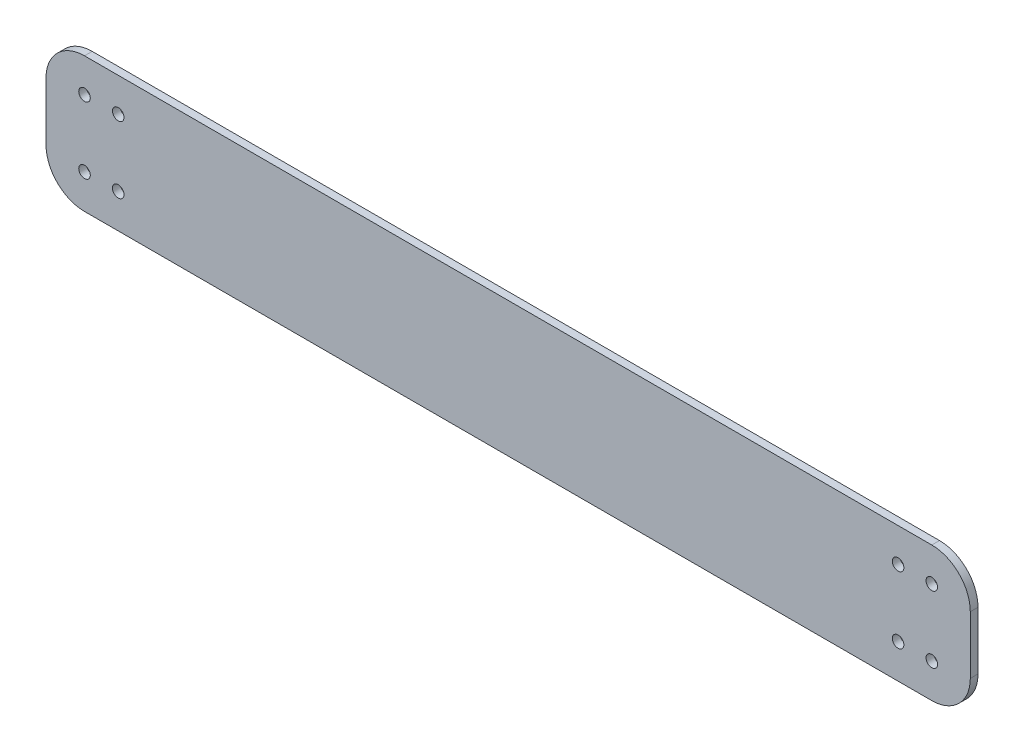
from build123d import *

# Parameters (mm, degrees)
EXTRUDE_1_DEPTH = 2
MM_2_D          = 3
MM_3_D          = 3


with BuildPart() as part:
    # 草图2 → 凸台-拉伸1 (new body)
    with BuildSketch(Plane.XY):
        with BuildLine():
            Line((-50.360367403, 22.370399323), (169.639632597, 22.370399323))
            ThreePointArc((169.639632597, 22.370399323), (176.710700409, 19.441467134), (179.639632597, 12.370399323))
            Line((179.639632597, 12.370399323), (179.639632597, -2.629600677))
            ThreePointArc((179.639632597, -2.629600677), (176.710700409, -9.700668489), (169.639632597, -12.629600677))
            Line((169.639632597, -12.629600677), (-50.360367403, -12.629600677))
            ThreePointArc((-50.360367403, -12.629600677), (-57.431435215, -9.700668489), (-60.360367403, -2.629600677))
            Line((-60.360367403, -2.629600677), (-60.360367403, 12.370399323))
            ThreePointArc((-60.360367403, 12.370399323), (-57.431435215, 19.441467134), (-50.360367403, 22.370399323))
        make_face()
    extrude(amount=EXTRUDE_1_DEPTH)

    # 大小mm 暗销孔2 (through all)
    with Locations(Plane(origin=(-41.610367403, 13.620399323, 0), x_dir=(-1, 0, 0), z_dir=(0, 0, -1))):
        with Locations((0, 0), (8.75, 0), (0, -17.352577314), (8.75, -17.352577314)):
            Hole(MM_2_D / 2)

    # 大小mm 暗销孔3 (through all)
    with Locations(Plane(origin=(169.639632597, 13.620399323, 0), x_dir=(-1, 0, 0), z_dir=(0, 0, -1))):
        with Locations((0, 0), (8.75, 0), (8.75, -17.352577314), (0, -17.352577314)):
            Hole(MM_3_D / 2)


solid = part.part
